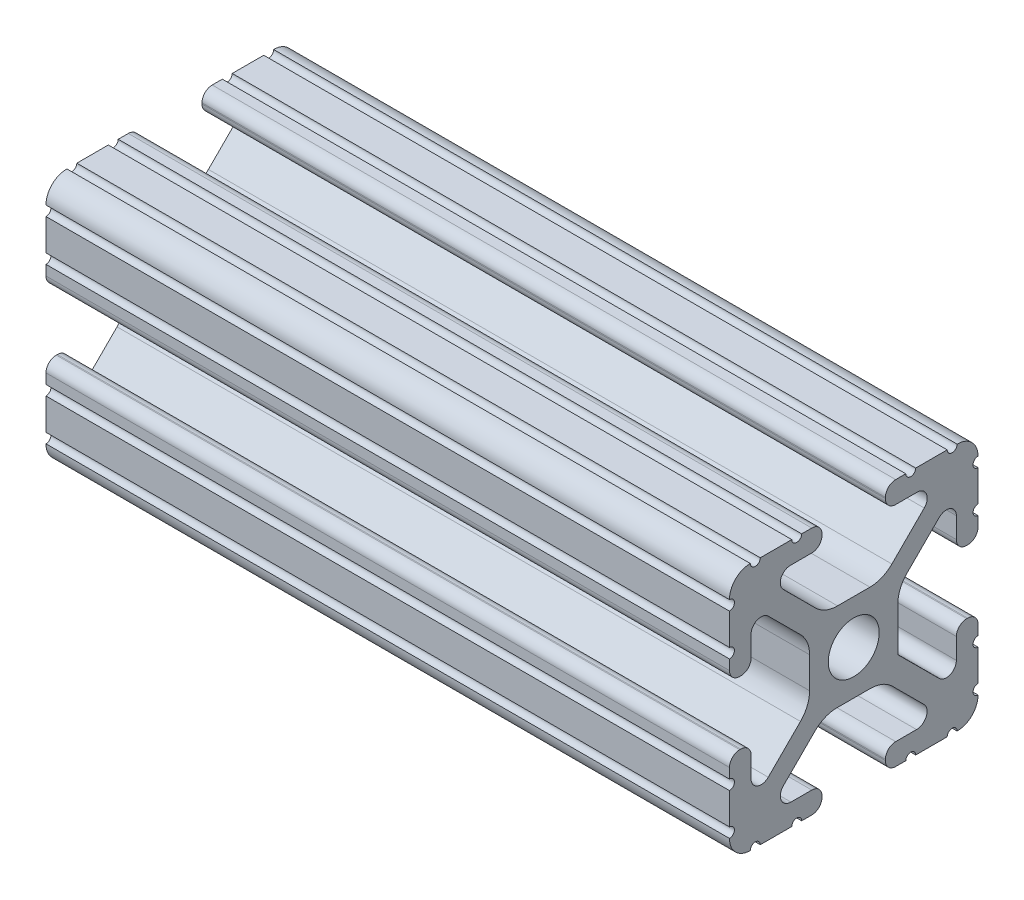
from build123d import *

# Parameters (mm, degrees)
SKETCH1_R           = 2.6035
BOSS_EXTRUDE1_DEPTH = 69.85


with BuildPart() as part:
    # Sketch1 → Boss-Extrude1 (new body)
    with BuildSketch(Plane(origin=(0, 0, 0), x_dir=(0, 0, -1), z_dir=(1, 0, 0))):
        with BuildLine():
            Line((6.333126718, -12.7), (9.550443118, -12.7))
            ThreePointArc((9.550443118, -12.7), (10.058366869, -12.192000006), (10.566443095, -12.699847501))
            ThreePointArc((10.566443095, -12.699847501), (12.082537762, -12.08250727), (12.699846982, -10.566399977))
            ThreePointArc((12.699846982, -10.566399977), (12.192000006, -10.058323491), (12.7, -9.5504))
            Line((12.7, -9.5504), (12.7, -6.3330836))
            ThreePointArc((12.7, -6.3330836), (12.192, -5.8250836), (12.7, -5.3170836))
            Line((12.7, -5.3170836), (12.7, -4.287469289))
            ThreePointArc((12.7, -4.287469289), (12.39275138, -3.545705502), (11.650987593, -3.238456882))
            Line((11.650987593, -3.238456882), (11.539212407, -3.238456882))
            ThreePointArc((11.539212407, -3.238456882), (10.79744862, -3.545705502), (10.4902, -4.287469289))
            Line((10.4902, -4.287469289), (10.4902, -6.402089023))
            ThreePointArc((10.4902, -6.402089023), (9.856505071, -7.351067942), (8.737131347, -7.129408934))
            Line((8.737131347, -7.129408934), (4.5085, -2.9104418))
            Line((4.5085, -2.9104418), (4.5085, 1.593185507))
            ThreePointArc((4.5085, 1.593185507), (4.750877967, 2.809883091), (5.441005833, 3.840816462))
            Line((5.441005833, 3.840816462), (8.737131347, 7.129408934))
            ThreePointArc((8.737131347, 7.129408934), (9.856505071, 7.351067942), (10.4902, 6.402089023))
            Line((10.4902, 6.402089023), (10.4902, 4.287469289))
            ThreePointArc((10.4902, 4.287469289), (10.79744862, 3.545705502), (11.539212407, 3.238456882))
            Line((11.539212407, 3.238456882), (11.650987593, 3.238456882))
            ThreePointArc((11.650987593, 3.238456882), (12.39275138, 3.545705502), (12.7, 4.287469289))
            Line((12.7, 4.287469289), (12.7, 5.3170836))
            ThreePointArc((12.7, 5.3170836), (12.192, 5.8250836), (12.7, 6.3330836))
            Line((12.7, 6.3330836), (12.7, 9.5504))
            ThreePointArc((12.7, 9.5504), (12.192000006, 10.058323491), (12.699846982, 10.566399977))
            ThreePointArc((12.699846982, 10.566399977), (12.082537762, 12.08250727), (10.566443095, 12.699847501))
            ThreePointArc((10.566443095, 12.699847501), (10.058366869, 12.192000006), (9.550443118, 12.7))
            Line((9.550443118, 12.7), (6.333126718, 12.7))
            ThreePointArc((6.333126718, 12.7), (5.825126718, 12.192), (5.317126718, 12.7))
            Line((5.317126718, 12.7), (4.287512407, 12.7))
            ThreePointArc((4.287512407, 12.7), (3.54574862, 12.39275138), (3.2385, 11.650987593))
            Line((3.2385, 11.650987593), (3.2385, 11.539212407))
            ThreePointArc((3.2385, 11.539212407), (3.54574862, 10.79744862), (4.287512407, 10.4902))
            Line((4.287512407, 10.4902), (6.476788598, 10.4902))
            ThreePointArc((6.476788598, 10.4902), (7.432222385, 9.85140422), (7.207036008, 8.724370562))
            Line((7.207036008, 8.724370562), (3.898272566, 5.423169045))
            ThreePointArc((3.898272566, 5.423169045), (2.869120213, 4.736787962), (1.655778399, 4.4958))
            Line((1.655778399, 4.4958), (-1.655778399, 4.4958))
            ThreePointArc((-1.655778399, 4.4958), (-2.869120213, 4.736787962), (-3.898272566, 5.423169045))
            Line((-3.898272566, 5.423169045), (-7.207036008, 8.724370562))
            ThreePointArc((-7.207036008, 8.724370562), (-7.432222385, 9.85140422), (-6.476788598, 10.4902))
            Line((-6.476788598, 10.4902), (-4.287512407, 10.4902))
            ThreePointArc((-4.287512407, 10.4902), (-3.54574862, 10.79744862), (-3.2385, 11.539212407))
            Line((-3.2385, 11.539212407), (-3.2385, 11.650987593))
            ThreePointArc((-3.2385, 11.650987593), (-3.54574862, 12.39275138), (-4.287512407, 12.7))
            Line((-4.287512407, 12.7), (-5.317126718, 12.7))
            ThreePointArc((-5.317126718, 12.7), (-5.825126718, 12.192), (-6.333126718, 12.7))
            Line((-6.333126718, 12.7), (-9.550443118, 12.7))
            ThreePointArc((-9.550443118, 12.7), (-10.058366869, 12.192000006), (-10.566443095, 12.699847501))
            ThreePointArc((-10.566443095, 12.699847501), (-12.082537762, 12.08250727), (-12.699846982, 10.566399977))
            ThreePointArc((-12.699846982, 10.566399977), (-12.192000006, 10.058323491), (-12.7, 9.5504))
            Line((-12.7, 9.5504), (-12.7, 6.3330836))
            ThreePointArc((-12.7, 6.3330836), (-12.192, 5.8250836), (-12.7, 5.3170836))
            Line((-12.7, 5.3170836), (-12.7, 4.287469289))
            ThreePointArc((-12.7, 4.287469289), (-12.39275138, 3.545705502), (-11.650987593, 3.238456882))
            Line((-11.650987593, 3.238456882), (-11.539212407, 3.238456882))
            ThreePointArc((-11.539212407, 3.238456882), (-10.79744862, 3.545705502), (-10.4902, 4.287469289))
            Line((-10.4902, 4.287469289), (-10.4902, 6.402089023))
            ThreePointArc((-10.4902, 6.402089023), (-9.856505071, 7.351067942), (-8.737131347, 7.129408934))
            Line((-8.737131347, 7.129408934), (-5.441005833, 3.840816462))
            ThreePointArc((-5.441005833, 3.840816462), (-4.750877967, 2.809883091), (-4.5085, 1.593185507))
            Line((-4.5085, 1.593185507), (-4.5085, -1.593185507))
            ThreePointArc((-4.5085, -1.593185507), (-4.750877967, -2.809883091), (-5.441005833, -3.840816462))
            Line((-5.441005833, -3.840816462), (-8.737131347, -7.129408934))
            ThreePointArc((-8.737131347, -7.129408934), (-9.856505071, -7.351067942), (-10.4902, -6.402089023))
            Line((-10.4902, -6.402089023), (-10.4902, -4.287469289))
            ThreePointArc((-10.4902, -4.287469289), (-10.79744862, -3.545705502), (-11.539212407, -3.238456882))
            Line((-11.539212407, -3.238456882), (-11.650987593, -3.238456882))
            ThreePointArc((-11.650987593, -3.238456882), (-12.39275138, -3.545705502), (-12.7, -4.287469289))
            Line((-12.7, -4.287469289), (-12.7, -5.3170836))
            ThreePointArc((-12.7, -5.3170836), (-12.192, -5.8250836), (-12.7, -6.3330836))
            Line((-12.7, -6.3330836), (-12.7, -9.5504))
            ThreePointArc((-12.7, -9.5504), (-12.192000006, -10.058323491), (-12.699846982, -10.566399977))
            ThreePointArc((-12.699846982, -10.566399977), (-12.082537762, -12.08250727), (-10.566443095, -12.699847501))
            ThreePointArc((-10.566443095, -12.699847501), (-10.058366869, -12.192000006), (-9.550443118, -12.7))
            Line((-9.550443118, -12.7), (-6.333126718, -12.7))
            ThreePointArc((-6.333126718, -12.7), (-5.825126718, -12.192), (-5.317126718, -12.7))
            Line((-5.317126718, -12.7), (-4.287512407, -12.7))
            ThreePointArc((-4.287512407, -12.7), (-3.54574862, -12.39275138), (-3.2385, -11.650987593))
            Line((-3.2385, -11.650987593), (-3.2385, -11.539212407))
            ThreePointArc((-3.2385, -11.539212407), (-3.54574862, -10.79744862), (-4.287512407, -10.4902))
            Line((-4.287512407, -10.4902), (-6.416408329, -10.4902))
            ThreePointArc((-6.416408329, -10.4902), (-7.41473083, -9.822813117), (-7.179650497, -8.645192506))
            Line((-7.179650497, -8.645192506), (-3.952270251, -5.423690499))
            ThreePointArc((-3.952270251, -5.423690499), (-2.922936451, -4.736929036), (-1.709253557, -4.4958))
            Line((-1.709253557, -4.4958), (1.709253557, -4.4958))
            ThreePointArc((1.709253557, -4.4958), (2.922936451, -4.736929036), (3.952270251, -5.423690499))
            Line((3.952270251, -5.423690499), (7.179650497, -8.645192506))
            ThreePointArc((7.179650497, -8.645192506), (7.41473083, -9.822813117), (6.416408329, -10.4902))
            Line((6.416408329, -10.4902), (4.287512407, -10.4902))
            ThreePointArc((4.287512407, -10.4902), (3.54574862, -10.79744862), (3.2385, -11.539212407))
            Line((3.2385, -11.539212407), (3.2385, -11.650987593))
            ThreePointArc((3.2385, -11.650987593), (3.54574862, -12.39275138), (4.287512407, -12.7))
            Line((4.287512407, -12.7), (5.317126718, -12.7))
            ThreePointArc((5.317126718, -12.7), (5.825126718, -12.192), (6.333126718, -12.7))
        make_face()
        Circle(SKETCH1_R, mode=Mode.SUBTRACT)
    extrude(amount=BOSS_EXTRUDE1_DEPTH)


solid = part.part
